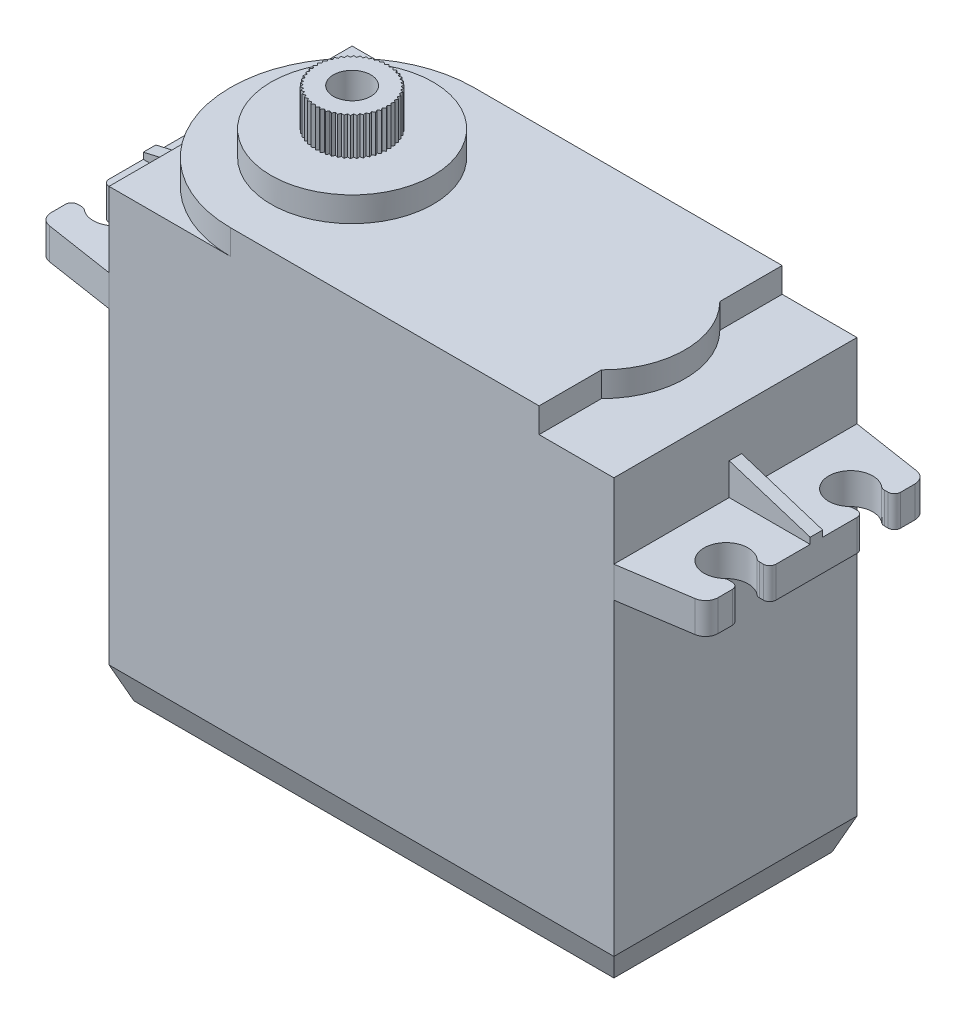
from build123d import *

# Parameters (mm, degrees)
SKETCH1_W                = 40.5
SKETCH1_H                = 19.5
BOSS_EXTRUDE1_DEPTH      = 35.75
BOSS_EXTRUDE2_START      = -6
BOSS_EXTRUDE2_DEPTH      = 2.5
BOSS_EXTRUDE3_DEPTH      = 0.5
BOSS_EXTRUDE3_DEPTH_BACK = 0.5
FILLET1_R                = 1
FILLET3_R                = 0.5
CHAMFER2_SIZE            = 1
CHAMFER2_SIZE2           = 2.5
BOSS_EXTRUDE4_DEPTH      = 2
SKETCH5_R                = 6.5
BOSS_EXTRUDE5_DEPTH      = 2
SKETCH6_R                = 2.75
BOSS_EXTRUDE6_DEPTH      = 3
SKETCH7_R                = 1.5
CUT_EXTRUDE1_DEPTH       = 3
BOSS_EXTRUDE7_DEPTH      = 3
CIRPATTERN1_COUNT        = 50
SKETCH9_W                = 7
SKETCH9_H                = 3
BOSS_EXTRUDE8_DEPTH      = 5
BOSS_EXTRUDE8_DEPTH_BACK = 3
CHAMFER4_SIZE            = 3.5
CHAMFER4_SIZE2           = 0.25
CHAMFER4_PART_2_SIZE     = 3.5
CHAMFER4_PART_2_SIZE2    = 0.25
CHAMFER4_PART_3_SIZE     = 3.5
CHAMFER4_PART_3_SIZE2    = 0.25
CHAMFER4_PART_4_SIZE     = 3.5
CHAMFER4_PART_4_SIZE2    = 0.25


with BuildPart() as part:
    # Sketch1 → Boss-Extrude1 (new body)
    with BuildSketch(Plane(origin=(0, 0, 0), x_dir=(1, 0, 0), z_dir=(0, 1, 0))):
        Rectangle(SKETCH1_W, SKETCH1_H)
    extrude(amount=BOSS_EXTRUDE1_DEPTH)

    # Sketch2 → Boss-Extrude2 (add)
    with BuildSketch(Plane(origin=(0, 35.75, 0), x_dir=(1, 0, 0), z_dir=(0, 1, 0)).offset(BOSS_EXTRUDE2_START)):
        with BuildLine():
            Line((-26.75, 8.75), (-26.75, 6.25))
            Line((-26.75, 6.25), (-25.75, 6.25))
            ThreePointArc((-25.75, 6.25), (-22.732233047, 5), (-25.75, 3.75))
            Line((-25.75, 3.75), (-26.75, 3.75))
            Line((-26.75, 3.75), (-26.75, -3.75))
            Line((-26.75, -3.75), (-25.75, -3.75))
            ThreePointArc((-25.75, -3.75), (-22.732233047, -5), (-25.75, -6.25))
            Line((-25.75, -6.25), (-26.75, -6.25))
            Line((-26.75, -6.25), (-26.75, -8.75))
            Line((-26.75, -8.75), (-20.25, -9.75))
            Line((-20.25, -9.75), (-20.25, 9.75))
            Line((-20.25, 9.75), (-26.75, 8.75))
        make_face()
        with BuildLine():
            Line((20.25, 9.75), (26.75, 8.75))
            Line((26.75, 8.75), (26.75, 6.25))
            Line((26.75, 6.25), (25.75, 6.25))
            ThreePointArc((25.75, 6.25), (22.732233047, 5), (25.75, 3.75))
            Line((25.75, 3.75), (26.75, 3.75))
            Line((26.75, 3.75), (26.75, -3.75))
            Line((26.75, -3.75), (25.75, -3.75))
            ThreePointArc((25.75, -3.75), (22.732233047, -5), (25.75, -6.25))
            Line((25.75, -6.25), (26.75, -6.25))
            Line((26.75, -6.25), (26.75, -8.75))
            Line((26.75, -8.75), (20.25, -9.75))
            Line((20.25, -9.75), (20.25, 9.75))
        make_face()
    extrude(amount=-BOSS_EXTRUDE2_DEPTH)

    # Sketch3 → Boss-Extrude3 (add, two sides)
    with BuildSketch(Plane.XY) as boss_extrude3_sk:
        Polygon((-26.75, 29.75), (-26.75, 30.25), (-20.25, 31.75), (-20.25, 29.75), align=None)
        Polygon((20.25, 29.75), (20.25, 32.308912064), (26.75, 30.25), (26.75, 29.75), align=None)
    extrude(amount=BOSS_EXTRUDE3_DEPTH)
    extrude(boss_extrude3_sk.sketch, amount=-BOSS_EXTRUDE3_DEPTH_BACK)

    # Fillet1
    fillet1_edges = [part.edges().sort_by_distance(p)[0] for p in [
        (-26.75, 28.5, -8.75),
        (-26.75, 28.5, 8.75),
        (26.75, 28.5, -8.75),
        (26.75, 28.5, 8.75),
    ]]
    fillet(fillet1_edges, radius=FILLET1_R)

    # Fillet3
    fillet3_edges = [part.edges().sort_by_distance(p)[0] for p in [
        (-25.75, 28.5, -3.75),
        (-25.75, 28.5, -6.25),
        (-26.75, 28.5, -6.25),
        (-26.75, 28.5, 6.25),
        (-25.75, 28.5, 6.25),
        (-25.75, 28.5, 3.75),
        (-26.75, 28.5, 3.75),
        (-26.75, 28.5, -3.75),
        (26.75, 28.5, -6.25),
        (25.75, 28.5, -6.25),
        (25.75, 28.5, -3.75),
        (26.75, 28.5, -3.75),
        (26.75, 28.5, 3.75),
        (25.75, 28.5, 3.75),
        (25.75, 28.5, 6.25),
        (26.75, 28.5, 6.25),
    ]]
    fillet(fillet3_edges, radius=FILLET3_R)

    # Chamfer2
    chamfer2_edges = [part.edges().sort_by_distance(p)[0] for p in [
        (0, 0, 9.75),
        (-20.25, 0, 0),
        (0, 0, -9.75),
        (20.25, 0, 0),
    ]]
    chamfer2_side = [part.faces().sort_by_distance(p)[0] for p in [
        (0, 0, 0),
    ]]
    chamfer(chamfer2_edges, length=CHAMFER2_SIZE, length2=CHAMFER2_SIZE2, reference=chamfer2_side[0])

    # Sketch4 → Boss-Extrude4 (add)
    with BuildSketch(Plane(origin=(0, 35.75, 0), x_dir=(1, 0, 0), z_dir=(0, 1, 0))):
        with BuildLine():
            Line((-10.5, -9.75), (14.25, -9.75))
            Line((14.25, -9.75), (14.25, -4.75))
            ThreePointArc((14.25, -4.75), (16.217514421, 0), (14.25, 4.75))
            Line((14.25, 4.75), (14.25, 9.75))
            Line((14.25, 9.75), (-10.5, 9.75))
            ThreePointArc((-10.5, 9.75), (-20.25, 0), (-10.5, -9.75))
        make_face()
    extrude(amount=BOSS_EXTRUDE4_DEPTH)

    # Sketch5 → Boss-Extrude5 (add)
    with BuildSketch(Plane(origin=(0, 37.75, 0), x_dir=(1, 0, 0), z_dir=(0, 1, 0))):
        with Locations((-10.5, 0)):
            Circle(SKETCH5_R)
    extrude(amount=BOSS_EXTRUDE5_DEPTH)

    # Sketch6 → Boss-Extrude6 (add)
    with BuildSketch(Plane(origin=(0, 39.75, 0), x_dir=(1, 0, 0), z_dir=(0, 1, 0))):
        with Locations((-10.5, 0)):
            Circle(SKETCH6_R)
    extrude(amount=BOSS_EXTRUDE6_DEPTH)

    # Sketch7 → Cut-Extrude1 (cut)
    with BuildSketch(Plane(origin=(0, 42.75, 0), x_dir=(1, 0, 0), z_dir=(0, 1, 0))):
        with Locations((-10.5, 0)):
            Circle(SKETCH7_R)
    extrude(amount=-CUT_EXTRUDE1_DEPTH, mode=Mode.SUBTRACT)

    # Sketch8 → Boss-Extrude7 (add)
    with BuildSketch(Plane(origin=(0, 42.75, 0), x_dir=(1, 0, 0), z_dir=(0, 1, 0))):
        Polygon((-10.5, 2.95), (-10.29213259, 2.74213259), (-10.70786741, 2.74213259), align=None)
    boss_extrude7 = extrude(amount=-BOSS_EXTRUDE7_DEPTH)

    # CirPattern1: Boss-Extrude7 ×50 about axis
    cirpattern1_axis = Axis((-10.5, 0, 0), (0, 1, 0))
    for i in range(1, CIRPATTERN1_COUNT):
        add(boss_extrude7.rotate(cirpattern1_axis, i * 360 / CIRPATTERN1_COUNT))

    # Sketch9 → Boss-Extrude8 (add, two sides)
    with BuildSketch(Plane.ZY.offset(20.25)) as boss_extrude8_sk:
        with Locations((0, 2.5)):
            Rectangle(SKETCH9_W, SKETCH9_H)
    extrude(amount=BOSS_EXTRUDE8_DEPTH)
    extrude(boss_extrude8_sk.sketch, amount=-BOSS_EXTRUDE8_DEPTH_BACK)

    # Chamfer4
    chamfer4_edges = [part.edges().sort_by_distance(p)[0] for p in [
        (-25.25, 2.5, 3.5),
    ]]
    chamfer4_side = [part.faces().sort_by_distance(p)[0] for p in [
        (-22.671359223, 2.470873786, 3.5),
    ]]
    chamfer(chamfer4_edges, length=CHAMFER4_SIZE, length2=CHAMFER4_SIZE2, reference=chamfer4_side[0])

    # Chamfer4 part 2
    chamfer4_part_2_edges = [part.edges().sort_by_distance(p)[0] for p in [
        (-25.25, 4, 0),
    ]]
    chamfer4_part_2_side = [part.faces().sort_by_distance(p)[0] for p in [
        (-22.75, 4, 0),
    ]]
    chamfer(chamfer4_part_2_edges, length=CHAMFER4_PART_2_SIZE, length2=CHAMFER4_PART_2_SIZE2, reference=chamfer4_part_2_side[0])

    # Chamfer4 part 3
    chamfer4_part_3_edges = [part.edges().sort_by_distance(p)[0] for p in [
        (-25.25, 2.5, -3.5),
    ]]
    chamfer4_part_3_side = [part.faces().sort_by_distance(p)[0] for p in [
        (-22.671359223, 2.470873786, -3.5),
    ]]
    chamfer(chamfer4_part_3_edges, length=CHAMFER4_PART_3_SIZE, length2=CHAMFER4_PART_3_SIZE2, reference=chamfer4_part_3_side[0])

    # Chamfer4 part 4
    chamfer4_part_4_edges = [part.edges().sort_by_distance(p)[0] for p in [
        (-25.25, 1, 0),
    ]]
    chamfer4_part_4_side = [part.faces().sort_by_distance(p)[0] for p in [
        (-22.45, 1, 0),
    ]]
    chamfer(chamfer4_part_4_edges, length=CHAMFER4_PART_4_SIZE, length2=CHAMFER4_PART_4_SIZE2, reference=chamfer4_part_4_side[0])


solid = part.part
